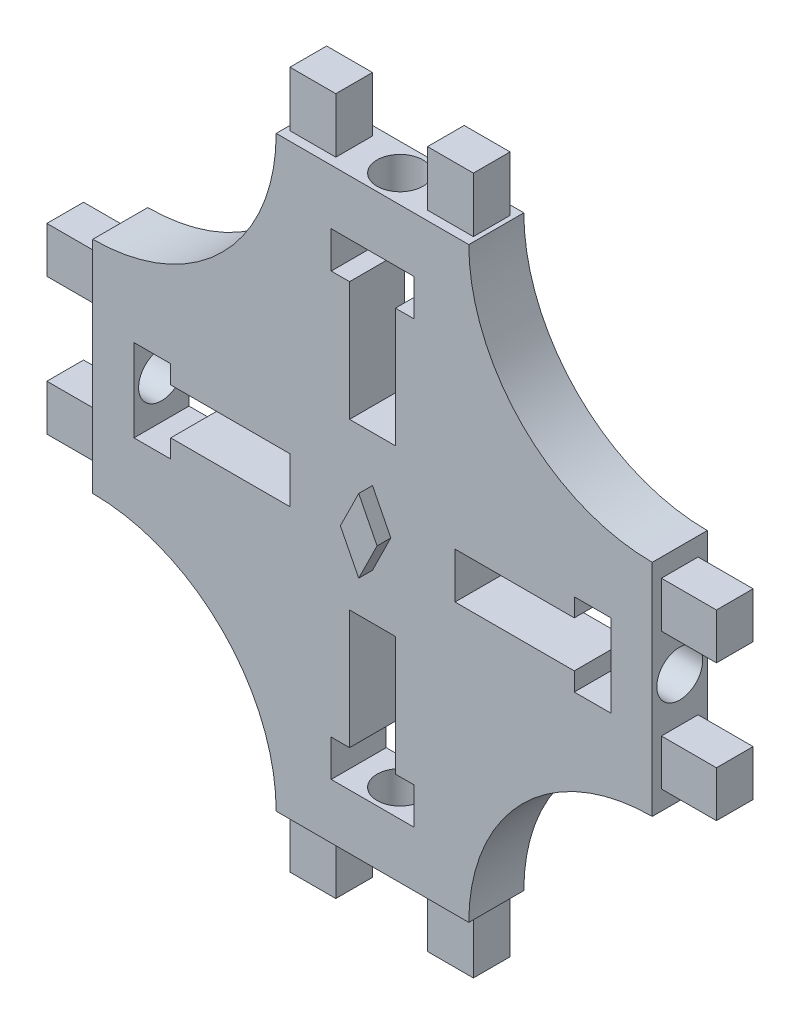
from build123d import *

# Parameters (mm, degrees)
EXTRUDE_2_DEPTH          = 3
SKETCH_2_R               = 1.25
CUT_EXTRUDE_1_DEPTH      = 4
PATTERN_CIRCULAR_1_COUNT = 4
EXTRUDE_3_DEPTH          = 0.75
SKETCH_4_W               = 2.5
SKETCH_4_H               = 2
EXTRUDE_5_DEPTH          = 3
PATTERN_LINEAR_1_COUNT   = 2
PATTERN_LINEAR_1_PITCH   = 35
SKETCH_5_W               = 2
SKETCH_5_H               = 2.5
EXTRUDE_6_DEPTH          = 3
PATTERN_LINEAR_2_COUNT   = 2
PATTERN_LINEAR_2_PITCH   = 33.5


with BuildPart() as part:
    # 草图1 → 凸台-拉伸2 (new body)
    with BuildSketch(Plane.XY):
        with BuildLine():
            Line((-5.25, -16), (-5, -16))
            Line((-5, -16), (0, -16))
            Line((0, -16), (5, -16))
            Line((5, -16), (5.25, -16))
            ThreePointArc((5.25, -16), (8.178932188, -8.928932188), (15.25, -6))
            Line((15.25, -6), (15.25, -5))
            Line((15.25, -5), (15.25, 0))
            Line((15.25, 0), (15.25, 5))
            Line((15.25, 5), (15.25, 6))
            ThreePointArc((15.25, 6), (8.178932188, 8.928932188), (5.25, 16))
            Line((5.25, 16), (5, 16))
            Line((5, 16), (0, 16))
            Line((0, 16), (-5, 16))
            Line((-5, 16), (-5.25, 16))
            ThreePointArc((-5.25, 16), (-8.178932188, 8.928932188), (-15.25, 6))
            Line((-15.25, 6), (-15.25, 5))
            Line((-15.25, 5), (-15.25, 0))
            Line((-15.25, 0), (-15.25, -5))
            Line((-15.25, -5), (-15.25, -6))
            ThreePointArc((-15.25, -6), (-8.178932188, -8.928932188), (-5.25, -16))
        make_face()
        Polygon((-1.25, -11), (-1.25, -4.5), (1.25, -4.5), (1.25, -11), (2.25, -11), (2.25, -13), (0, -13), (-2.25, -13), (-2.25, -11), align=None, mode=Mode.SUBTRACT)
        Polygon((-11, -2.25), (-13, -2.25), (-13, 0), (-13, 2.25), (-11, 2.25), (-11, 1.25), (-4.5, 1.25), (-4.5, -1.25), (-11, -1.25), align=None, mode=Mode.SUBTRACT)
        Polygon((4.5, -1.25), (4.5, 1.25), (11, 1.25), (11, 2.25), (13, 2.25), (13, 0), (13, -2.25), (11, -2.25), (11, -1.25), align=None, mode=Mode.SUBTRACT)
        Polygon((-2.25, 11), (-2.25, 13), (0, 13), (2.25, 13), (2.25, 11), (1.25, 11), (1.25, 4.5), (-1.25, 4.5), (-1.25, 11), align=None, mode=Mode.SUBTRACT)
    extrude(amount=EXTRUDE_2_DEPTH)

    # 草图2 → 切除-拉伸1 (cut)
    with BuildSketch(Plane(origin=(0, 16, 0), x_dir=(1, 0, 0), z_dir=(0, 1, 0))):
        with Locations((0, -1.5)):
            Circle(SKETCH_2_R)
    cut_extrude_1 = extrude(amount=-CUT_EXTRUDE_1_DEPTH, mode=Mode.SUBTRACT)

    # 阵列(圆周)1: 切除-拉伸1 ×4 about axis
    pattern_circular_1_axis = Axis((0, 0, 3), (0, 0, 1))
    for i in range(1, PATTERN_CIRCULAR_1_COUNT):
        add(cut_extrude_1.rotate(pattern_circular_1_axis, i * 360 / PATTERN_CIRCULAR_1_COUNT), mode=Mode.SUBTRACT)

    # 草图3 → 凸台-拉伸3 (add)
    with BuildSketch(Plane.XY.offset(3)):
        Polygon((1, 0.025113601), (0, 0), (0, 2), align=None)
        Polygon((-1, -0.025113601), (0, 2), (0, 0), align=None)
        Polygon((-1, -0.025113601), (0, 0), (0, -2), align=None)
        Polygon((1, 0.025113601), (0, -2), (0, 0), align=None)
    extrude(amount=EXTRUDE_3_DEPTH)

    # 草图4 → 凸台-拉伸5 (add)
    with BuildSketch(Plane(origin=(0, 16, 0), x_dir=(1, 0, 0), z_dir=(0, 1, 0))):
        with Locations((3.75, -1.5)):
            Rectangle(SKETCH_4_W, SKETCH_4_H)
        with Locations((-3.75, -1.5)):
            Rectangle(SKETCH_4_W, SKETCH_4_H)
    extrude_5 = extrude(amount=EXTRUDE_5_DEPTH)

    # 阵列(线性)1: 凸台-拉伸5 ×2
    with Locations(*[(0, -i * PATTERN_LINEAR_1_PITCH, 0) for i in range(1, PATTERN_LINEAR_1_COUNT)]):
        add(extrude_5)

    # 草图5 → 凸台-拉伸6 (add)
    with BuildSketch(Plane(origin=(15.25, 0, 0), x_dir=(0, 0, -1), z_dir=(1, 0, 0))):
        with Locations((-1.5, 3.75)):
            Rectangle(SKETCH_5_W, SKETCH_5_H)
        with Locations((-1.5, -3.699772798)):
            Rectangle(SKETCH_5_W, SKETCH_5_H)
    extrude_6 = extrude(amount=EXTRUDE_6_DEPTH)

    # 阵列(线性)2: 凸台-拉伸6 ×2
    with Locations(*[(-i * PATTERN_LINEAR_2_PITCH, 0, 0) for i in range(1, PATTERN_LINEAR_2_COUNT)]):
        add(extrude_6)


solid = part.part
